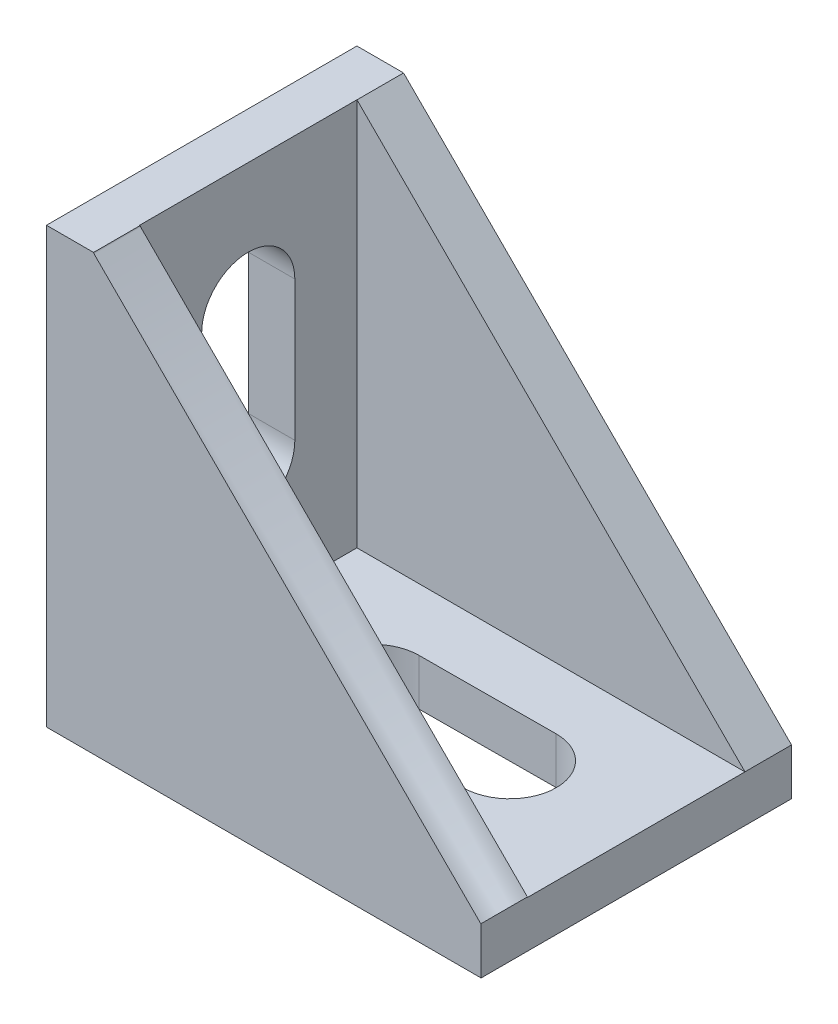
from build123d import *

# Parameters (mm, degrees)
SKETCH1_W           = 28
SKETCH1_H           = 20
BOSS_EXTRUDE1_DEPTH = 3
SKETCH2_W           = 3
SKETCH2_H           = 20
BOSS_EXTRUDE2_DEPTH = 25
SKETCH3_W           = 25
SKETCH3_H           = 3
BOSS_EXTRUDE3_DEPTH = 25
CUT_EXTRUDE1_DEPTH  = 25
CUT_EXTRUDE2_DEPTH  = 25
CUT_EXTRUDE3_DEPTH  = 25
CUT_EXTRUDE4_DEPTH  = 25


with BuildPart() as part:
    # Sketch1 → Boss-Extrude1 (new body)
    with BuildSketch(Plane(origin=(0, 0, 0), x_dir=(1, 0, 0), z_dir=(0, 1, 0))):
        with Locations((0.825174825, 2.237762238)):
            Rectangle(SKETCH1_W, SKETCH1_H)
    extrude(amount=BOSS_EXTRUDE1_DEPTH)

    # Sketch2 → Boss-Extrude2 (add)
    with BuildSketch(Plane(origin=(0, 3, 0), x_dir=(1, 0, 0), z_dir=(0, 1, 0))):
        with Locations((-11.674825175, 2.237762238)):
            Rectangle(SKETCH2_W, SKETCH2_H)
    extrude(amount=BOSS_EXTRUDE2_DEPTH)

    # Sketch3 → Boss-Extrude3 (add)
    with BuildSketch(Plane(origin=(0, 3, 0), x_dir=(1, 0, 0), z_dir=(0, 1, 0))):
        with Locations((2.325174825, -6.262237762)):
            Rectangle(SKETCH3_W, SKETCH3_H)
        with Locations((2.325174825, 10.737762238)):
            Rectangle(SKETCH3_W, SKETCH3_H)
    extrude(amount=BOSS_EXTRUDE3_DEPTH)

    # Sketch4 → Cut-Extrude1 (cut)
    with BuildSketch(Plane.XY.offset(-9.237762238)):
        with BuildLine():
            add(Edge.make_bspline(
                [(14.816368242, 3.008806583), (6.487903216, 11.337271609), (-1.840561809, 19.665736635), (-10.169026835, 27.99420166), (-10.16964342, 27.994818245), (-10.170781245, 27.99595607), (-10.170656704, 27.998996051), (-10.170343396, 28)],
                knots=[0, 0, 0, 0, 0.344046384, 0.344046384, 0.344046384, 0.344071855, 0.344093387, 0.344093387, 0.344093387, 0.344093387], degree=3))
            add(Edge.make_bspline(
                [(14.825174825, 3.004378162), (14.823896916, 3.004464678), (14.819965163, 3.005209662), (14.817823619, 3.007351206), (14.816368242, 3.008806583)],
                knots=[0.999911533, 0.999911533, 0.999911533, 0.999911533, 0.999939879, 1, 1, 1, 1], degree=3))
            Line((14.825174825, 3.004378162), (14.825174825, 28))
            Line((14.825174825, 28), (-10.170343396, 28))
        make_face()
    extrude(amount=-CUT_EXTRUDE1_DEPTH, mode=Mode.SUBTRACT)

    # Sketch5 → Cut-Extrude2 (cut)
    with BuildSketch(Plane(origin=(0, 0, 4.762237762), x_dir=(-1, 0, 0), z_dir=(0, 0, -1))):
        with BuildLine():
            add(Edge.make_bspline(
                [(-35.067252589, 33.961212886), (-29.391038068, 36.178470487), (-23.714823548, 38.395728089), (-18.038609027, 40.612985691), (-17.963791349, 40.642211165), (-17.814155994, 40.700662115), (-17.559065615, 40.718177611), (-17.399544187, 40.699199542), (-17.319783474, 40.689710508), (-10.209359532, 39.843792085), (-3.09893559, 38.997873662), (4.011488351, 38.151955239), (4.046454663, 38.14779534), (4.116387287, 38.139475541), (4.223224946, 38.0698289), (4.25905817, 38.009200763), (4.276974782, 37.978886695), (6.22420547, 34.684263552), (8.171436157, 31.389640408), (10.118666845, 28.095017265), (10.128528722, 28.078331431), (10.148252475, 28.044959763), (10.137896266, 27.963071091), (10.11048555, 27.935660375), (10.096780192, 27.921955017), (1.809823102, 19.634997927), (-6.477133988, 11.348040838), (-14.764091077, 3.061083748), (-14.773689462, 3.051485363), (-14.792886232, 3.032288593), (-14.857463418, 3.032288593), (-14.876660188, 3.051485363), (-14.886258573, 3.061083748), (-16.63085756, 4.805682735), (-18.375456547, 6.550281721), (-20.120055533, 8.294880708), (-20.229166807, 8.403991982), (-20.447389354, 8.622214529), (-20.734044746, 8.995724629), (-20.888397332, 9.262965044), (-20.965573625, 9.396585251), (-25.677007414, 17.553789146), (-30.388441203, 25.71099304), (-35.099874992, 33.868196935), (-35.105352774, 33.877680966), (-35.116308338, 33.896649028), (-35.097857424, 33.949257946), (-35.077454201, 33.957227906), (-35.067252589, 33.961212886)],
                knots=[0, 0, 0, 0, 0.146383908, 0.146383908, 0.146383908, 0.148313382, 0.150242855, 0.152172328, 0.152172328, 0.152172328, 0.324178973, 0.324178973, 0.324178973, 0.325024835, 0.325870697, 0.326716559, 0.326716559, 0.326716559, 0.418647366, 0.418647366, 0.418647366, 0.419112956, 0.419578546, 0.420044135, 0.420044135, 0.420044135, 0.701563293, 0.701563293, 0.701563293, 0.701889363, 0.702215434, 0.702541504, 0.702541504, 0.702541504, 0.761807895, 0.761807895, 0.761807895, 0.765514552, 0.76922121, 0.772927868, 0.772927868, 0.772927868, 0.999210732, 0.999210732, 0.999210732, 0.999473821, 0.999736911, 1, 1, 1, 1], degree=3))
        make_face()
    extrude(amount=-CUT_EXTRUDE2_DEPTH, mode=Mode.SUBTRACT)

    # Sketch6 → Cut-Extrude3 (cut)
    with BuildSketch(Plane(origin=(-10.174825175, 0, 0), x_dir=(0, 0, -1), z_dir=(1, 0, 0))):
        with BuildLine():
            Line((-0.762237762, 11), (-0.762237762, 20))
            ThreePointArc((-0.762237762, 20), (2.237762238, 23), (5.237762238, 20))
            Line((5.237762238, 20), (5.237762238, 11))
            ThreePointArc((5.237762238, 11), (2.237762238, 8), (-0.762237762, 11))
        make_face()
    extrude(amount=-CUT_EXTRUDE3_DEPTH, mode=Mode.SUBTRACT)

    # Sketch7 → Cut-Extrude4 (cut)
    with BuildSketch(Plane(origin=(0, 3, 0), x_dir=(1, 0, 0), z_dir=(0, 1, 0))):
        with BuildLine():
            Line((6.643802614, -0.720378412), (-2.16057373, -0.762203911))
            ThreePointArc((-2.16057373, -0.762203911), (-5.174791324, 2.223510793), (-2.189076619, 5.237728387))
            Line((-2.189076619, 5.237728387), (6.615299725, 5.279553886))
            ThreePointArc((6.615299725, 5.279553886), (9.629517318, 2.293839181), (6.643802614, -0.720378412))
        make_face()
    extrude(amount=-CUT_EXTRUDE4_DEPTH, mode=Mode.SUBTRACT)


solid = part.part
